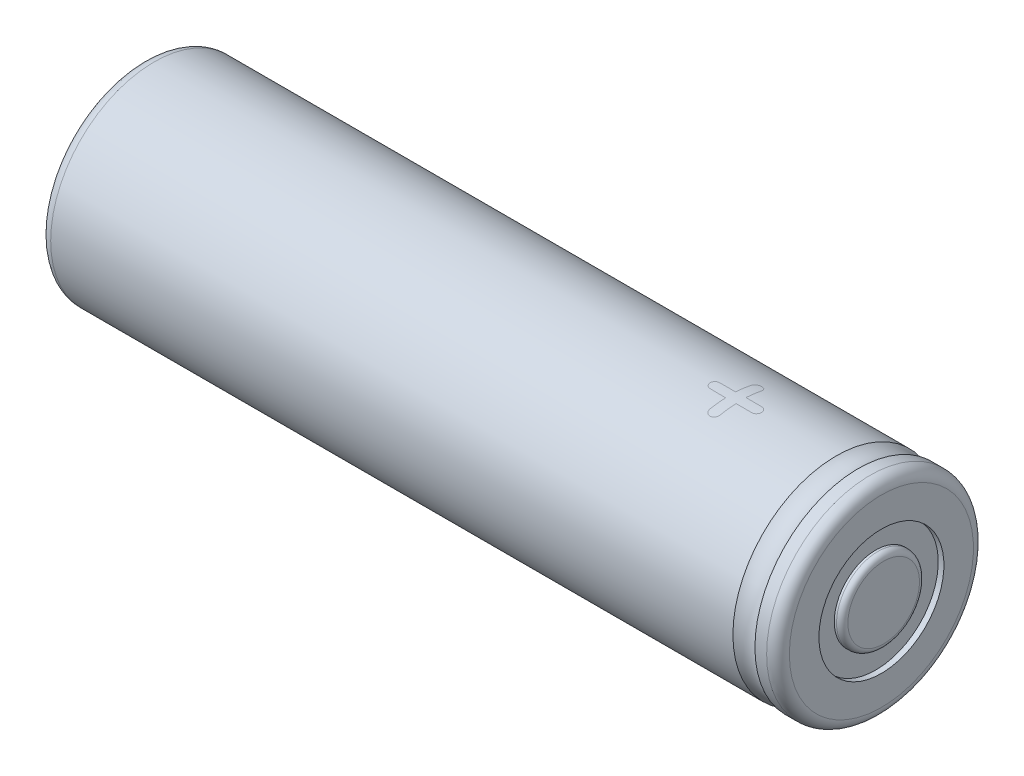
from build123d import *

# Parameters (mm, degrees)
SKETCH2_W = 0.699473795
SKETCH2_H = 3.65
FILLET1_R = 0.5


with BuildPart() as part:
    # Sketch1 → mainBody (revolve)
    with BuildSketch(Plane(origin=(0, 0, 0), x_dir=(1, 0, 0), z_dir=(0, 1, 0))):
        with BuildLine():
            Line((-30.015877082, 9.1), (30.015877082, 9.1))
            ThreePointArc((30.015877082, 9.1), (30.984122918, 8.85), (31.952368755, 9.1))
            Line((31.952368755, 9.1), (32.984122918, 9.1))
            ThreePointArc((32.984122918, 9.1), (33.691229699, 8.807106781), (33.984122918, 8.1))
            Line((33.984122918, 8.1), (33.984122918, 5.5))
            Line((33.984122918, 5.5), (33.484649123, 5.5))
            Line((33.484649123, 5.5), (33.484649123, 0))
            Line((33.484649123, 0), (-30.715877082, 0))
            Line((-30.715877082, 0), (-30.715877082, 5.5))
            Line((-30.715877082, 5.5), (-31.015877082, 5.5))
            Line((-31.015877082, 5.5), (-31.015877082, 8.1))
            ThreePointArc((-31.015877082, 8.1), (-30.722983863, 8.807106781), (-30.015877082, 9.1))
        make_face()
    revolve(axis=Axis((0, 0, 0), (1, 0, 0)))

    # Sketch2 → Revolve2 (revolve)
    with BuildSketch(Plane(origin=(0, 0, 0), x_dir=(1, 0, 0), z_dir=(0, 1, 0))):
        with Locations((33.834386021, 1.825)):
            Rectangle(SKETCH2_W, SKETCH2_H)
    revolve(axis=Axis((33.484649123, 0, 0), (1, 0, 0)))

    # Fillet1
    fillet1_edges = [part.edges().sort_by_distance(p)[0] for p in [
        (34.184122918, 0, 3.65),
    ]]
    fillet(fillet1_edges, radius=FILLET1_R)


solid = part.part
